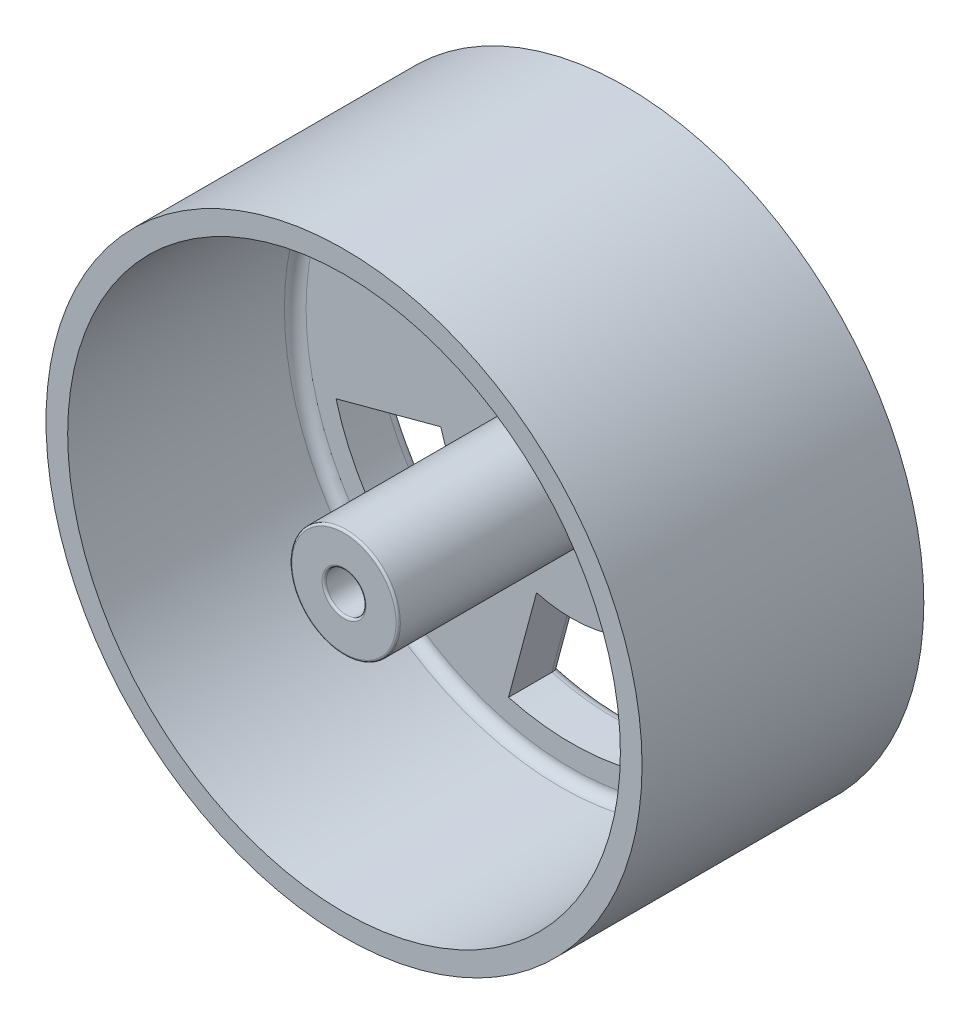
from build123d import *

# Parameters (mm, degrees)
SKETCH1_R           = 27.5
BOSS_EXTRUDE1_DEPTH = 5
SKETCH2_R           = 27.5
SKETCH2_R_2         = 25.5
SKETCH2_R_3         = 5
BOSS_EXTRUDE3_DEPTH = 26
SKETCH3_R           = 1.83
CUT_EXTRUDE1_DEPTH  = 5.3
FILLET1_R           = 1
FILLET2_R           = 1
SKETCH4_R           = 4
CUT_EXTRUDE2_DEPTH  = 1
FILLET3_R           = 0.2


with BuildPart() as part:
    # Sketch1 → Boss-Extrude1 (new body)
    with BuildSketch(Plane.XY):
        Circle(SKETCH1_R)
        with BuildLine():
            Line((-5.823428515, 21.733331092), (-3.235238064, 12.074072829))
            ThreePointArc((-3.235238064, 12.074072829), (0, 12.5), (3.235238064, 12.074072829))
            Line((3.235238064, 12.074072829), (5.823428515, 21.733331092))
            ThreePointArc((5.823428515, 21.733331092), (0, 22.5), (-5.823428515, 21.733331092))
        make_face(mode=Mode.SUBTRACT)
        with BuildLine():
            Line((15.909902577, 15.909902577), (8.838834765, 8.838834765))
            ThreePointArc((8.838834765, 8.838834765), (10.825317547, 6.25), (12.074072829, 3.235238064))
            Line((12.074072829, 3.235238064), (21.733331092, 5.823428515))
            ThreePointArc((21.733331092, 5.823428515), (19.485571585, 11.25), (15.909902577, 15.909902577))
        make_face(mode=Mode.SUBTRACT)
        with BuildLine():
            Line((21.733331092, -5.823428515), (12.074072829, -3.235238064))
            ThreePointArc((12.074072829, -3.235238064), (10.825317547, -6.25), (8.838834765, -8.838834765))
            Line((8.838834765, -8.838834765), (15.909902577, -15.909902577))
            ThreePointArc((15.909902577, -15.909902577), (19.485571585, -11.25), (21.733331092, -5.823428515))
        make_face(mode=Mode.SUBTRACT)
        with BuildLine():
            Line((5.823428515, -21.733331092), (3.235238064, -12.074072829))
            ThreePointArc((3.235238064, -12.074072829), (0, -12.5), (-3.235238064, -12.074072829))
            Line((-3.235238064, -12.074072829), (-5.823428515, -21.733331092))
            ThreePointArc((-5.823428515, -21.733331092), (0, -22.5), (5.823428515, -21.733331092))
        make_face(mode=Mode.SUBTRACT)
        with BuildLine():
            Line((-15.909902577, -15.909902577), (-8.838834765, -8.838834765))
            ThreePointArc((-8.838834765, -8.838834765), (-10.825317547, -6.25), (-12.074072829, -3.235238064))
            Line((-12.074072829, -3.235238064), (-21.733331092, -5.823428515))
            ThreePointArc((-21.733331092, -5.823428515), (-19.485571585, -11.25), (-15.909902577, -15.909902577))
        make_face(mode=Mode.SUBTRACT)
        with BuildLine():
            Line((-21.733331092, 5.823428515), (-12.074072829, 3.235238064))
            ThreePointArc((-12.074072829, 3.235238064), (-10.825317547, 6.25), (-8.838834765, 8.838834765))
            Line((-8.838834765, 8.838834765), (-15.909902577, 15.909902577))
            ThreePointArc((-15.909902577, 15.909902577), (-19.485571585, 11.25), (-21.733331092, 5.823428515))
        make_face(mode=Mode.SUBTRACT)
    extrude(amount=BOSS_EXTRUDE1_DEPTH)

    # Sketch2 → Boss-Extrude3 (add)
    with BuildSketch(Plane.XY):
        Circle(SKETCH2_R)
        Circle(SKETCH2_R_2, mode=Mode.SUBTRACT)
        Circle(SKETCH2_R_3)
    extrude(amount=BOSS_EXTRUDE3_DEPTH)

    # Sketch3 → Cut-Extrude1 (cut)
    with BuildSketch(Plane.XY.offset(26)):
        Circle(SKETCH3_R)
    extrude(amount=-CUT_EXTRUDE1_DEPTH, mode=Mode.SUBTRACT)

    # Fillet1
    fillet1_edges = [part.edges().sort_by_distance(p)[0] for p in [
        (-25.5, 0, 5),
        (-5, 0, 5),
    ]]
    fillet(fillet1_edges, radius=FILLET1_R)

    # Fillet2
    fillet2_edges = [part.edges().sort_by_distance(p)[0] for p in [
        (4.529333289, 16.90370196, 5),
        (19.485571585, 11.25, 0),
        (12.374368671, 12.374368671, 0),
        (10.825317547, 6.25, 0),
        (16.90370196, 4.529333289, 0),
        (19.485571585, -11.25, 0),
        (16.90370196, -4.529333289, 0),
        (10.825317547, -6.25, 0),
        (12.374368671, -12.374368671, 0),
        (0, -22.5, 0),
        (4.529333289, -16.90370196, 0),
        (0, -12.5, 0),
        (-4.529333289, -16.90370196, 0),
        (-19.485571585, -11.25, 0),
        (-12.374368671, -12.374368671, 0),
        (-10.825317547, -6.25, 0),
        (-16.90370196, -4.529333289, 0),
        (-19.485571585, 11.25, 0),
        (-16.90370196, 4.529333289, 0),
        (-10.825317547, 6.25, 0),
        (-12.374368671, 12.374368671, 0),
        (0, 22.5, 0),
        (-4.529333289, 16.90370196, 0),
        (0, 12.5, 0),
        (4.529333289, 16.90370196, 0),
        (0, 22.5, 5),
        (-4.529333289, 16.90370196, 5),
        (0, 12.5, 5),
    ]]
    fillet(fillet2_edges, radius=FILLET2_R)

    # Sketch4 → Cut-Extrude2 (cut)
    with BuildSketch(Plane(origin=(0, 0, 0), x_dir=(-1, 0, 0), z_dir=(0, 0, -1))):
        Circle(SKETCH4_R)
    extrude(amount=-CUT_EXTRUDE2_DEPTH, mode=Mode.SUBTRACT)

    # Fillet3
    fillet3_edges = [part.edges().sort_by_distance(p)[0] for p in [
        (-1.83, 0, 20.7),
        (-1.83, 0, 26),
        (-5, 0, 26),
    ]]
    fillet(fillet3_edges, radius=FILLET3_R)


solid = part.part
